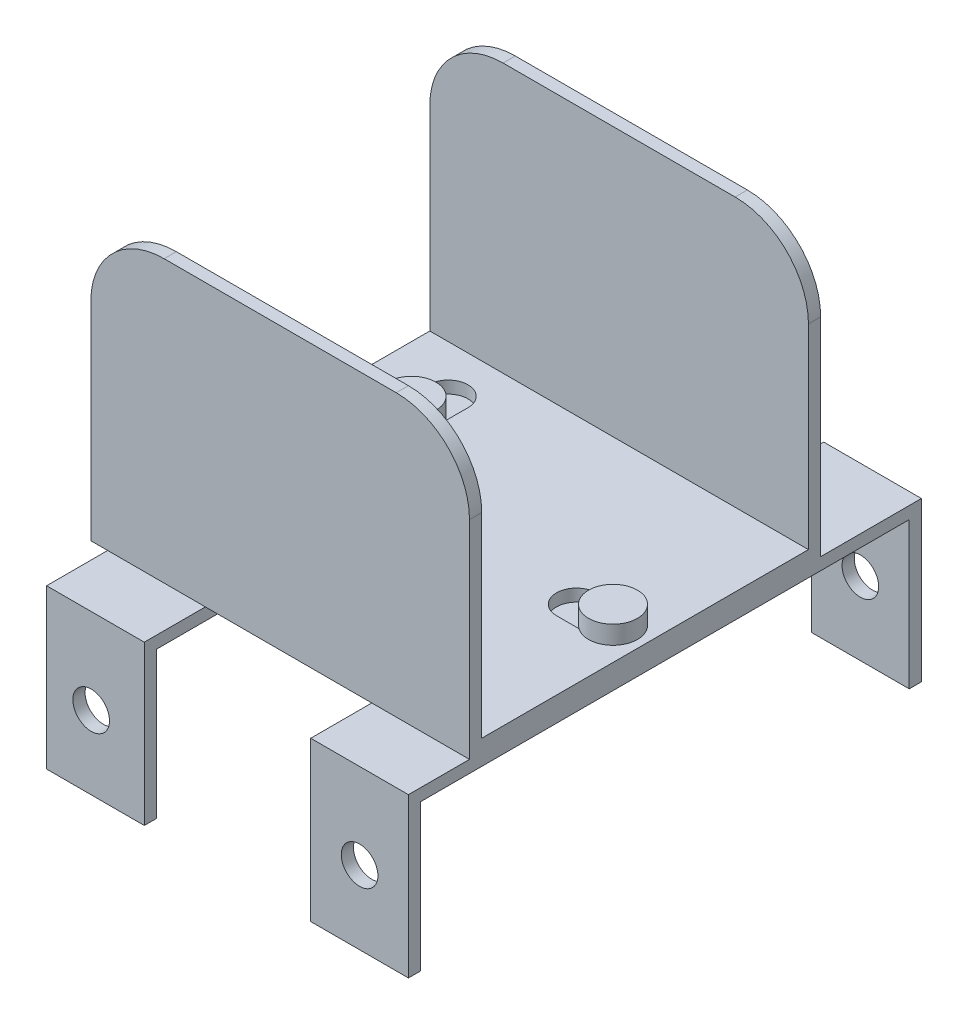
from build123d import *

# Parameters (mm, degrees)
SKETCH1_W               = 98.425
SKETCH1_H               = 91.28125
SKETCH1_R               = 5.159375
BOSS_EXTRUDE1_DEPTH     = 3.175
SKETCH2_W               = 25.4
SKETCH2_H               = 133.35
BOSS_EXTRUDE3_DEPTH     = 3.175
SKETCH3_W               = 25.4
SKETCH3_H               = 3.175
BOSS_EXTRUDE4_DEPTH     = 38.1
SKETCH4_R               = 4.7625
CUT_EXTRUDE1_DEPTH      = 134.35
SKETCH5_R               = 5.159375
BOSS_EXTRUDE5_DEPTH     = 9.525
SKETCH6_R               = 6.35
BOSS_EXTRUDE6_DEPTH     = 4.7625
SKETCH7_W               = 98.425
SKETCH7_H               = 3.175
BOSS_EXTRUDE7_DEPTH     = 69.85
CUT_EXTRUDE2_DEPTH      = 16.875
CUT_EXTRUDE2_DEPTH_BACK = 118.475


with BuildPart() as part:
    # Sketch1 → Boss-Extrude1 (new body)
    with BuildSketch(Plane(origin=(0, 0, 0), x_dir=(1, 0, 0), z_dir=(0, 1, 0))):
        with Locations((49.2125, 45.640625)):
            Rectangle(SKETCH1_W, SKETCH1_H)
        with Locations((17.065625, 45.640625)):
            Circle(SKETCH1_R, mode=Mode.SUBTRACT)
        with BuildLine():
            Line((11.90625, 66.278125), (11.90625, 75.803125))
            ThreePointArc((11.90625, 75.803125), (17.065625, 80.9625), (22.225, 75.803125))
            Line((22.225, 75.803125), (22.225, 66.278125))
            ThreePointArc((22.225, 66.278125), (17.065625, 61.11875), (11.90625, 66.278125))
        make_face(mode=Mode.SUBTRACT)
        with BuildLine():
            Line((11.90625, 25.003125), (11.90625, 15.478125))
            ThreePointArc((11.90625, 15.478125), (17.065625, 10.31875), (22.225, 15.478125))
            Line((22.225, 15.478125), (22.225, 25.003125))
            ThreePointArc((22.225, 25.003125), (17.065625, 30.1625), (11.90625, 25.003125))
        make_face(mode=Mode.SUBTRACT)
        with BuildLine():
            Line((80.565625, 50.8), (90.090625, 50.8))
            ThreePointArc((90.090625, 50.8), (95.25, 45.640625), (90.090625, 40.48125))
            Line((90.090625, 40.48125), (80.565625, 40.48125))
            ThreePointArc((80.565625, 40.48125), (75.40625, 45.640625), (80.565625, 50.8))
        make_face(mode=Mode.SUBTRACT)
    extrude(amount=BOSS_EXTRUDE1_DEPTH)

    # Sketch2 → Boss-Extrude3 (add)
    with BuildSketch(Plane.XZ):
        with Locations((17.065625, -50.8)):
            Rectangle(SKETCH2_W, SKETCH2_H)
        with Locations((85.725, -50.8)):
            Rectangle(SKETCH2_W, SKETCH2_H)
    extrude(amount=BOSS_EXTRUDE3_DEPTH)

    # Sketch3 → Boss-Extrude4 (add)
    with BuildSketch(Plane.XZ.offset(3.175)):
        with Locations((17.065625, 14.2875)):
            Rectangle(SKETCH3_W, SKETCH3_H)
        with Locations((17.065625, -115.8875)):
            Rectangle(SKETCH3_W, SKETCH3_H)
        with Locations((85.725, 14.2875)):
            Rectangle(SKETCH3_W, SKETCH3_H)
        with Locations((85.725, -115.8875)):
            Rectangle(SKETCH3_W, SKETCH3_H)
    extrude(amount=BOSS_EXTRUDE4_DEPTH)

    # Sketch4 → Cut-Extrude1 (cut, through all)
    with BuildSketch(Plane.XY.offset(15.875)):
        with Locations((15.95994836, -22.225)):
            Circle(SKETCH4_R)
        with Locations((85.725, -22.225)):
            Circle(SKETCH4_R)
    extrude(amount=-CUT_EXTRUDE1_DEPTH, mode=Mode.SUBTRACT)

    # Sketch5 → Boss-Extrude5 (add)
    with BuildSketch(Plane(origin=(0, 3.175, 0), x_dir=(1, 0, 0), z_dir=(0, 1, 0))):
        with Locations((17.065625, 45.640625)):
            Circle(SKETCH5_R)
        with Locations((17.065625, 66.278125)):
            Circle(SKETCH5_R)
        with Locations((90.090625, 45.640625)):
            Circle(SKETCH5_R)
    extrude(amount=-BOSS_EXTRUDE5_DEPTH)

    # Sketch6 → Boss-Extrude6 (add)
    with BuildSketch(Plane(origin=(0, 3.175, 0), x_dir=(1, 0, 0), z_dir=(0, 1, 0))):
        with Locations((90.090625, 45.640625)):
            Circle(SKETCH6_R)
        with Locations((17.065625, 45.640625)):
            Circle(SKETCH6_R)
        with Locations((17.065625, 66.278125)):
            Circle(SKETCH6_R)
    extrude(amount=BOSS_EXTRUDE6_DEPTH)

    # Sketch7 → Boss-Extrude7 (add)
    with BuildSketch(Plane(origin=(0, 3.175, 0), x_dir=(1, 0, 0), z_dir=(0, 1, 0))):
        with Locations((49.2125, 89.69375)):
            Rectangle(SKETCH7_W, SKETCH7_H)
        with Locations((49.2125, 1.5875)):
            Rectangle(SKETCH7_W, SKETCH7_H)
    extrude(amount=BOSS_EXTRUDE7_DEPTH)

    # Sketch8 → Cut-Extrude2 (cut, two sides)
    with BuildSketch(Plane.XY) as cut_extrude2_sk:
        with BuildLine():
            Line((79.375, 73.025), (98.425, 73.025))
            Line((98.425, 73.025), (98.425, 53.975))
            ThreePointArc((98.425, 53.975), (92.845384182, 67.445384182), (79.375, 73.025))
        make_face()
        with BuildLine():
            Line((19.05, 73.025), (0, 73.025))
            Line((0, 73.025), (0, 53.975))
            ThreePointArc((0, 53.975), (5.579615818, 67.445384182), (19.05, 73.025))
        make_face()
    extrude(amount=CUT_EXTRUDE2_DEPTH, mode=Mode.SUBTRACT)
    extrude(cut_extrude2_sk.sketch, amount=-CUT_EXTRUDE2_DEPTH_BACK, mode=Mode.SUBTRACT)


solid = part.part
